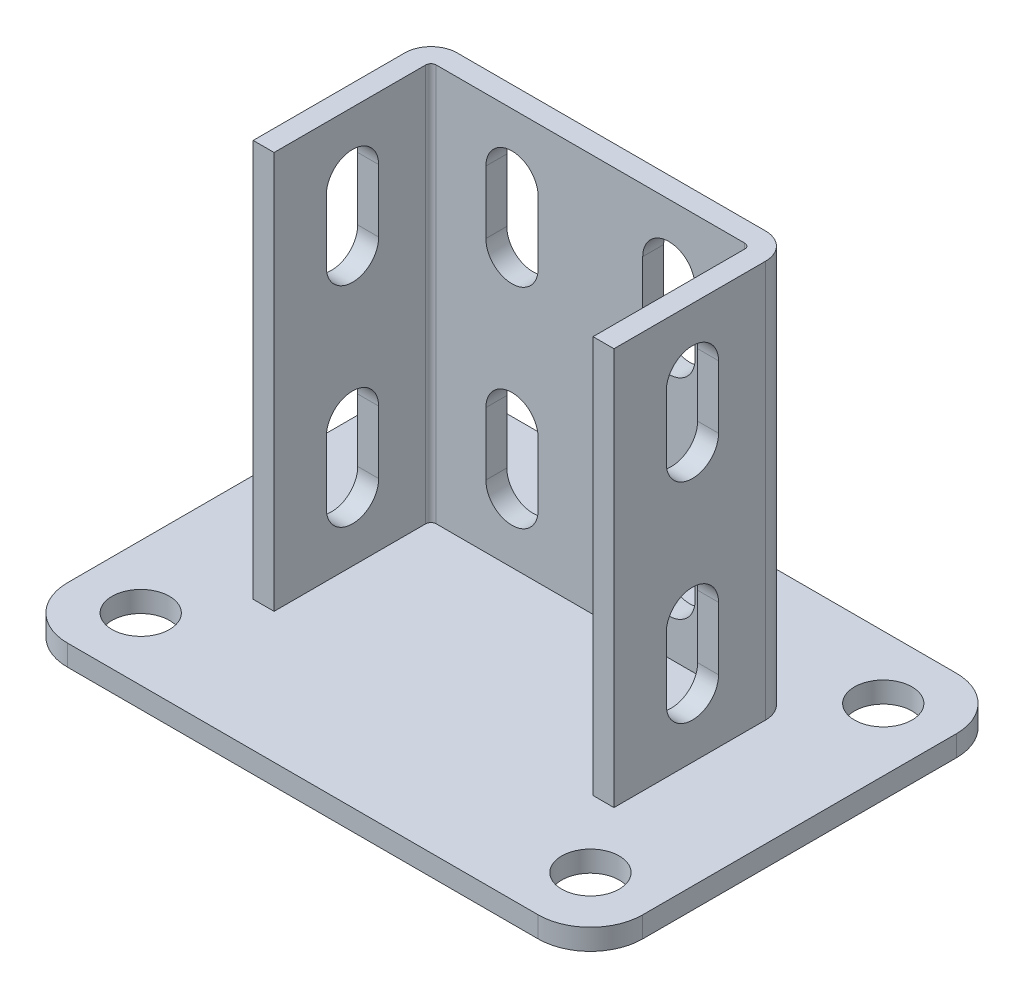
from build123d import *

# Parameters (mm, degrees)
SKETCH_2_W          = 110
SKETCH_2_H          = 80
EXTRUDE_1_DEPTH     = 4
EXTRUDE_1_2_DEPTH   = 76
EXTRUDE_2_DEPTH     = 2
CUT_EXTRUDE_1_DEPTH = 90.5
SKETCH_6_R          = 5.5
CUT_EXTRUDE_2_DEPTH = 5
FILLET_1_R          = 10
CUT_EXTRUDE_3_REACH = 61


with BuildPart() as part:
    # Эскиз2 → Extrude 1 (new body)
    with BuildSketch(Plane(origin=(0, 0, 0), x_dir=(1, 0, 0), z_dir=(0, 1, 0))):
        Rectangle(SKETCH_2_W, SKETCH_2_H)
    extrude(amount=EXTRUDE_1_DEPTH)

    # Эскиз3 → Extrude 1 2 (add)
    with BuildSketch(Plane(origin=(0, 4, 0), x_dir=(1, 0, 0), z_dir=(0, 1, 0))):
        with BuildLine():
            Line((-30.5, -15), (-30.5, 14))
            ThreePointArc((-30.5, 14), (-30.207106781, 14.707106781), (-29.5, 15))
            Line((-29.5, 15), (29.5, 15))
            ThreePointArc((29.5, 15), (30.207106781, 14.707106781), (30.5, 14))
            Line((30.5, 14), (30.5, -15))
            Line((30.5, -15), (34.5, -15))
            Line((34.5, -15), (34.5, 14))
            ThreePointArc((34.5, 14), (33.035533906, 17.535533906), (29.5, 19))
            Line((29.5, 19), (-29.5, 19))
            ThreePointArc((-29.5, 19), (-33.035533906, 17.535533906), (-34.5, 14))
            Line((-34.5, 14), (-34.5, -15))
            Line((-34.5, -15), (-30.5, -15))
        make_face()
    extrude(amount=EXTRUDE_1_2_DEPTH)

    # Эскиз4 → Бобышка-Вытянуть2 (add, symmetric)
    with BuildSketch(Plane(origin=(0, 0, 0), x_dir=(0, 0, -1), z_dir=(1, 0, 0))):
        Polygon((19, 31.712812921), (35, 4), (19, 4), align=None)
    extrude(amount=EXTRUDE_2_DEPTH, both=True)

    # Эскиз5 → Вырез-Вытянуть1 (cut, through all)
    with BuildSketch(Plane(origin=(34.5, 0, 0), x_dir=(0, 0, -1), z_dir=(1, 0, 0))):
        with BuildLine():
            Line((5, 68), (5, 56))
            ThreePointArc((5, 56), (0, 51), (-5, 56))
            Line((-5, 56), (-5, 68))
            ThreePointArc((-5, 68), (0, 73), (5, 68))
        make_face()
        with BuildLine():
            Line((5, 28), (5, 16))
            ThreePointArc((5, 16), (0, 11), (-5, 16))
            Line((-5, 16), (-5, 28))
            ThreePointArc((-5, 28), (0, 33), (5, 28))
        make_face()
    extrude(amount=-CUT_EXTRUDE_1_DEPTH, mode=Mode.SUBTRACT)

    # Эскиз6 → Вырез-Вытянуть2 (cut, through all)
    with BuildSketch(Plane(origin=(0, 4, 0), x_dir=(1, 0, 0), z_dir=(0, 1, 0))):
        with Locations(Location((-43, 28, 0), (0, 0, 270))):  # turned: the seam where the file's is
            Circle(SKETCH_6_R)
        with Locations(Location((-43, -28, 0), (0, 0, 270))):  # turned: the seam where the file's is
            Circle(SKETCH_6_R)
        with Locations(Location((43, 28, 0), (0, 0, 270))):  # turned: the seam where the file's is
            Circle(SKETCH_6_R)
        with Locations(Location((43, -28, 0), (0, 0, 270))):  # turned: the seam where the file's is
            Circle(SKETCH_6_R)
    extrude(amount=-CUT_EXTRUDE_2_DEPTH, mode=Mode.SUBTRACT)

    # Скругление1
    fillet_1_edges = [part.edges().sort_by_distance(p)[0] for p in [
        (55, 2, 40),
        (-55, 2, 40),
        (-55, 2, -40),
        (55, 2, -40),
    ]]
    fillet(fillet_1_edges, radius=FILLET_1_R)

    # Эскиз8 → Вырез-Вытянуть3 (cut, up to next)
    with BuildSketch(Plane(origin=(0, 0, -19), x_dir=(-1, 0, 0), z_dir=(0, 0, -1)), mode=Mode.PRIVATE) as cut_extrude_3_sk1:
        with BuildLine():
            Line((-10, 68), (-10, 56))
            ThreePointArc((-10, 56), (-15, 51), (-20, 56))
            Line((-20, 56), (-20, 68))
            ThreePointArc((-20, 68), (-15, 73), (-10, 68))
        make_face()
    cut_extrude_3_tool1 = extrude(cut_extrude_3_sk1.sketch, amount=-CUT_EXTRUDE_3_REACH, mode=Mode.PRIVATE) & part.part
    add(cut_extrude_3_tool1.solids().sort_by_distance((15, 62, -19))[0], mode=Mode.SUBTRACT)
    # Эскиз8 → Вырез-Вытянуть3 (cut, up to next)
    with BuildSketch(Plane(origin=(0, 0, -19), x_dir=(-1, 0, 0), z_dir=(0, 0, -1)), mode=Mode.PRIVATE) as cut_extrude_3_sk2:
        with BuildLine():
            Line((-10, 28), (-10, 16))
            ThreePointArc((-10, 16), (-15, 11), (-20, 16))
            Line((-20, 16), (-20, 28))
            ThreePointArc((-20, 28), (-15, 33), (-10, 28))
        make_face()
    cut_extrude_3_tool2 = extrude(cut_extrude_3_sk2.sketch, amount=-CUT_EXTRUDE_3_REACH, mode=Mode.PRIVATE) & part.part
    add(cut_extrude_3_tool2.solids().sort_by_distance((15, 22, -19))[0], mode=Mode.SUBTRACT)
    # Эскиз8 → Вырез-Вытянуть3 (cut, up to next)
    with BuildSketch(Plane(origin=(0, 0, -19), x_dir=(-1, 0, 0), z_dir=(0, 0, -1)), mode=Mode.PRIVATE) as cut_extrude_3_sk3:
        with BuildLine():
            Line((10, 68), (10, 56))
            ThreePointArc((10, 56), (15, 51), (20, 56))
            Line((20, 56), (20, 68))
            ThreePointArc((20, 68), (15, 73), (10, 68))
        make_face()
    cut_extrude_3_tool3 = extrude(cut_extrude_3_sk3.sketch, amount=-CUT_EXTRUDE_3_REACH, mode=Mode.PRIVATE) & part.part
    add(cut_extrude_3_tool3.solids().sort_by_distance((-15, 62, -19))[0], mode=Mode.SUBTRACT)
    # Эскиз8 → Вырез-Вытянуть3 (cut, up to next)
    with BuildSketch(Plane(origin=(0, 0, -19), x_dir=(-1, 0, 0), z_dir=(0, 0, -1)), mode=Mode.PRIVATE) as cut_extrude_3_sk4:
        with BuildLine():
            Line((10, 28), (10, 16))
            ThreePointArc((10, 16), (15, 11), (20, 16))
            Line((20, 16), (20, 28))
            ThreePointArc((20, 28), (15, 33), (10, 28))
        make_face()
    cut_extrude_3_tool4 = extrude(cut_extrude_3_sk4.sketch, amount=-CUT_EXTRUDE_3_REACH, mode=Mode.PRIVATE) & part.part
    add(cut_extrude_3_tool4.solids().sort_by_distance((-15, 22, -19))[0], mode=Mode.SUBTRACT)


solid = part.part
